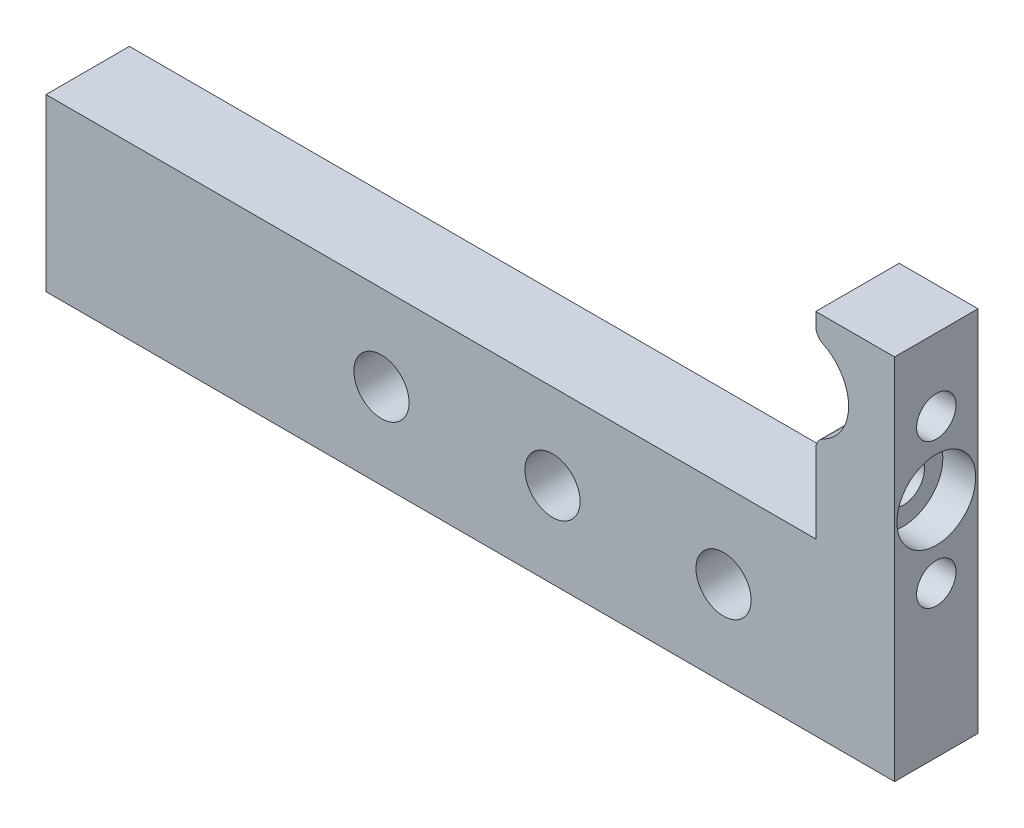
from build123d import *

# Parameters (mm, degrees)
SKETCH1_R           = 2.1
BOSS_EXTRUDE1_DEPTH = 6.35
SKETCH2_R           = 1.6
CUT_EXTRUDE1_DEPTH  = 65.6
SKETCH3_R           = 3
CUT_EXTRUDE2_DEPTH  = 2.5
SKETCH4_R           = 1.5
CUT_EXTRUDE3_DEPTH  = 5
FILLET1_R           = 1


with BuildPart() as part:
    # Sketch1 → Boss-Extrude1 (new body)
    with BuildSketch(Plane.XY):
        with BuildLine():
            Line((45.4, -16), (45.4, -29))
            Line((45.4, -29), (110, -29))
            Line((110, -29), (110, -1))
            Line((110, -1), (104, -1))
            Line((104, -1), (104, -2.645898034))
            ThreePointArc((104, -2.645898034), (106.5, -6), (104, -9.354101966))
            Line((104, -9.354101966), (104, -16))
            Line((104, -16), (99, -16))
            Line((99, -16), (45.4, -16))
        make_face()
        with Locations((96.978626472, -22.5)):
            Circle(SKETCH1_R, mode=Mode.SUBTRACT)
        with Locations((83.957252945, -22.5)):
            Circle(SKETCH1_R, mode=Mode.SUBTRACT)
        with Locations((70.935879417, -22.5)):
            Circle(SKETCH1_R, mode=Mode.SUBTRACT)
    extrude(amount=BOSS_EXTRUDE1_DEPTH)

    # Sketch2 → Cut-Extrude1 (cut, through all)
    with BuildSketch(Plane(origin=(110, 0, 0), x_dir=(0, 0, -1), z_dir=(1, 0, 0))):
        with Locations((-3.175, -12)):
            Circle(SKETCH2_R)
    extrude(amount=-CUT_EXTRUDE1_DEPTH, mode=Mode.SUBTRACT)

    # Sketch3 → Cut-Extrude2 (cut)
    with BuildSketch(Plane(origin=(110, 0, 0), x_dir=(0, 0, -1), z_dir=(1, 0, 0))):
        with Locations((-3.175, -12)):
            Circle(SKETCH3_R)
    extrude(amount=-CUT_EXTRUDE2_DEPTH, mode=Mode.SUBTRACT)

    # Sketch4 → Cut-Extrude3 (cut)
    with BuildSketch(Plane(origin=(110, 0, 0), x_dir=(0, 0, -1), z_dir=(1, 0, 0))):
        with Locations((-3.175, -17.5)):
            Circle(SKETCH4_R)
        with Locations((-3.175, -6.5)):
            Circle(SKETCH4_R)
    extrude(amount=-CUT_EXTRUDE3_DEPTH, mode=Mode.SUBTRACT)

    # Fillet1
    fillet1_edges = [part.edges().sort_by_distance(p)[0] for p in [
        (104, -9.354101966, 3.175),
        (104, -2.645898034, 3.175),
    ]]
    fillet(fillet1_edges, radius=FILLET1_R)


solid = part.part
